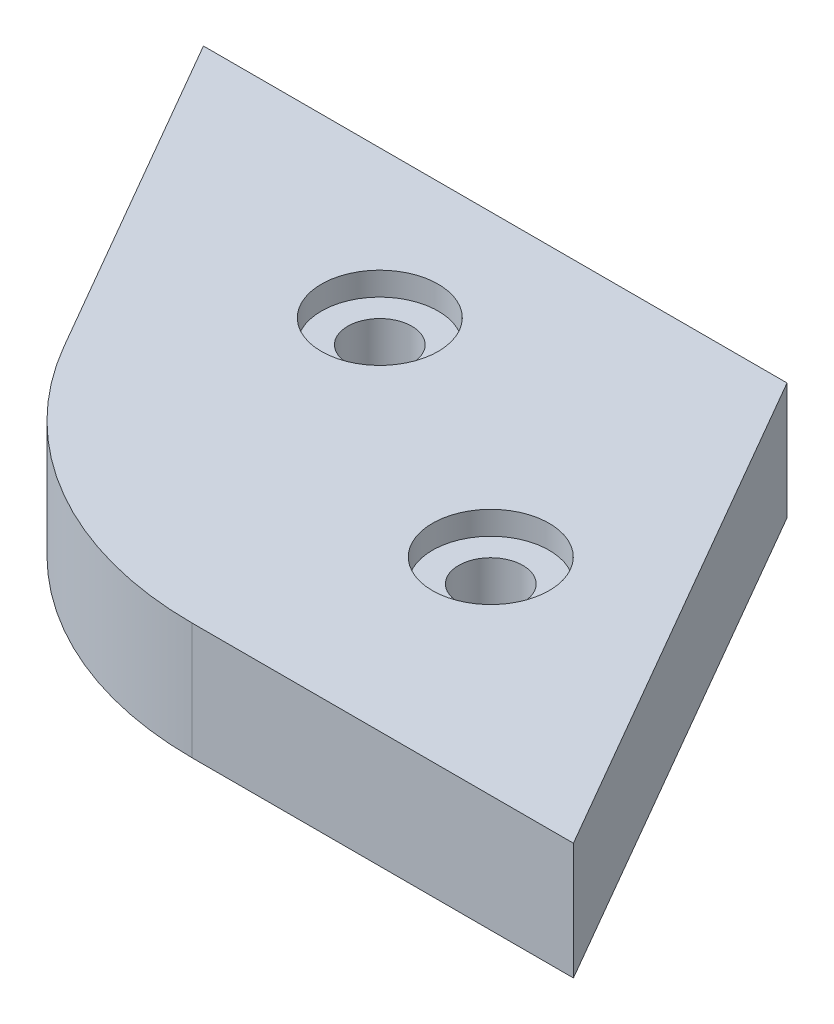
from build123d import *

# Parameters (mm, degrees)
CROQUIS1_R              = 2.75
SALIENTE_EXTRUIR1_DEPTH = 10
CROQUIS2_R              = 5
CORTAR_EXTRUIR1_DEPTH   = 2
REDONDEO1_R             = 30


with BuildPart() as part:
    # Croquis1 → Saliente-Extruir1 (new body)
    with BuildSketch(Plane(origin=(0, 0, 0), x_dir=(1, 0, 0), z_dir=(0, 1, 0))):
        Polygon((-148.723962655, -344.2), (-198.723962655, -344.2), (-223.723962655, -300.898729811), (-173.723962655, -300.898729811), align=None)
        with Locations((-173.50486289, -326.5)):
            Circle(CROQUIS1_R, mode=Mode.SUBTRACT)
        with Locations((-196.00486289, -313.509618943)):
            Circle(CROQUIS1_R, mode=Mode.SUBTRACT)
    extrude(amount=SALIENTE_EXTRUIR1_DEPTH)

    # Croquis2 → Cortar-Extruir1 (cut)
    with BuildSketch(Plane(origin=(0, 10, 0), x_dir=(1, 0, 0), z_dir=(0, 1, 0))):
        with Locations((-196.00486289, -313.509618943)):
            Circle(CROQUIS2_R)
        with Locations((-173.50486289, -326.5)):
            Circle(CROQUIS2_R)
    extrude(amount=-CORTAR_EXTRUIR1_DEPTH, mode=Mode.SUBTRACT)

    # Redondeo1
    redondeo1_edges = [part.edges().sort_by_distance(p)[0] for p in [
        (-198.723962655, 5, 344.2),
    ]]
    fillet(redondeo1_edges, radius=REDONDEO1_R)


solid = part.part
